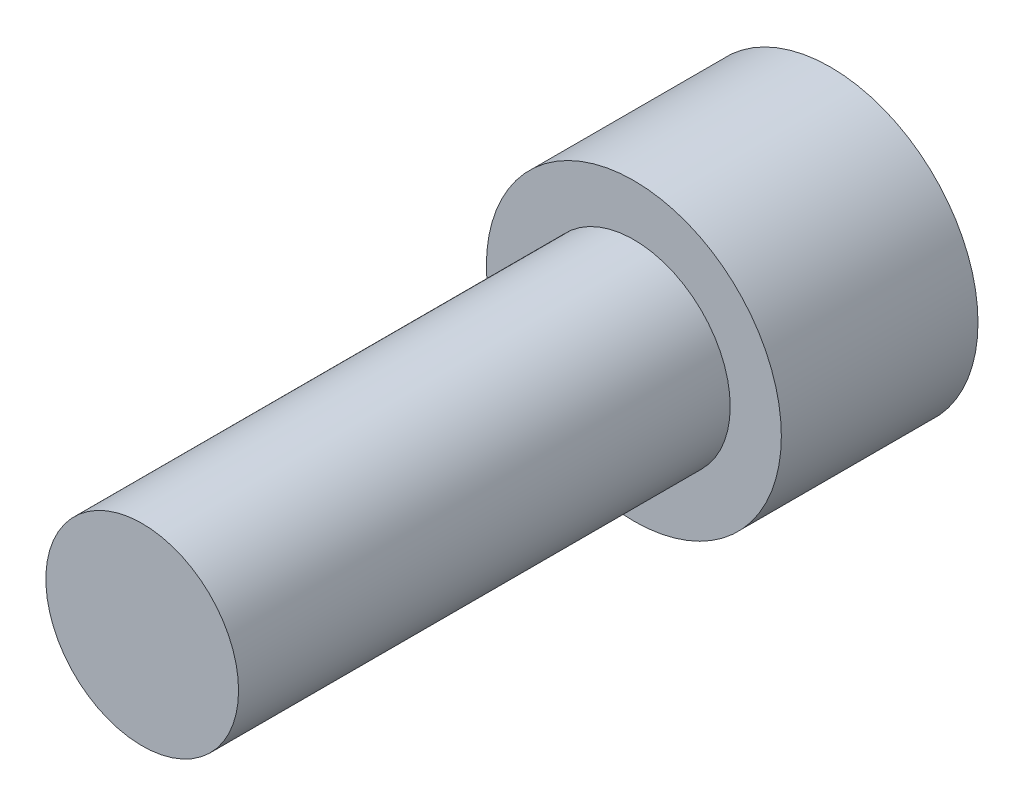
from build123d import *

# Parameters (mm, degrees)
SKETCH1_R         = 3.81
EXTRUDE1_DEPTH    = 17.78
SKETCH2_OUTSIDE_W = 13.778
SKETCH2_OUTSIDE_H = 13.778
SKETCH2_OUTSIDE_R = 2.4892
EXTRUDE2_DEPTH    = 12.7
EXTRUDE3_DEPTH    = 3.048


with BuildPart() as part:
    # Sketch1 → Extrude1 (new body)
    with BuildSketch(Plane.XY):
        Circle(SKETCH1_R)
    extrude(amount=EXTRUDE1_DEPTH)

    # Sketch2 outside → Extrude2 (cut)
    with BuildSketch(Plane.XY.offset(17.78)):
        Rectangle(SKETCH2_OUTSIDE_W, SKETCH2_OUTSIDE_H)
        Circle(SKETCH2_OUTSIDE_R, mode=Mode.SUBTRACT)
    extrude(amount=-EXTRUDE2_DEPTH, mode=Mode.SUBTRACT)

    # Sketch3 → Extrude3 (cut)
    with BuildSketch(Plane(origin=(0, 0, 0), x_dir=(-1, 0, 0), z_dir=(0, 0, -1))):
        Polygon((0, 2.987683948), (-2.587410198, 1.493841974), (-2.587410198, -1.493841974), (0, -2.987683948), (2.587410198, -1.493841974), (2.587410198, 1.493841974), align=None)
    extrude(amount=-EXTRUDE3_DEPTH, mode=Mode.SUBTRACT)


solid = part.part
